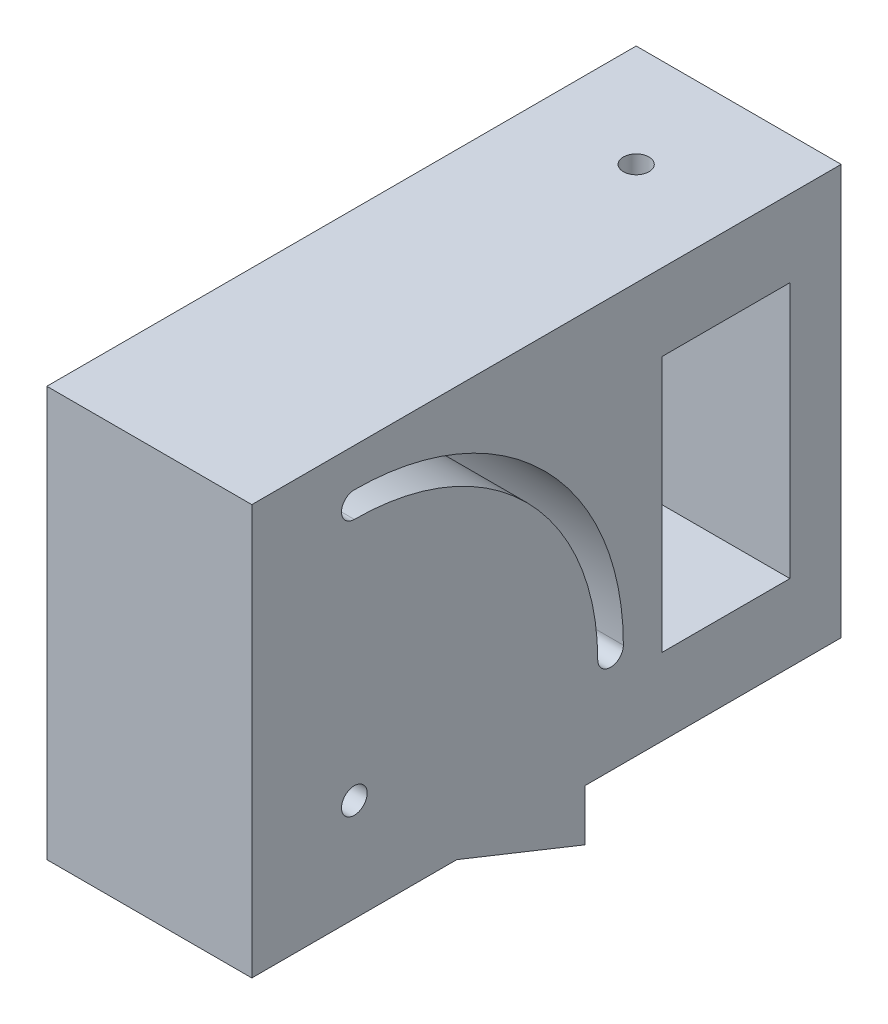
from build123d import *

# Parameters (mm, degrees)
SALIENTE_EXTRUIR1_DEPTH           = 40
CROQUIS2_W                        = 40
CROQUIS2_H                        = 80
SALIENTE_EXTRUIR2_DEPTH           = 50
CORTAR_EXTRUIR1_DEPTH             = 41
CROQUIS4_W                        = 25.000000038
CROQUIS4_H                        = 50
CORTAR_EXTRUIR2_DEPTH             = 41
DI_METRO_DE_TALADRO_5_0_5_1_D     = 5
DI_METRO_DE_TALADRO_5_0_5_1_DEPTH = 25.000025
DI_METRO_DE_TALADRO_5_0_5_2_D     = 5
DI_METRO_DE_TALADRO_5_0_5_2_DEPTH = 40.00005
DI_METRO_DE_TALADRO_5_0_5_3_D     = 5
DI_METRO_DE_TALADRO_5_0_5_3_DEPTH = 90.000025


with BuildPart() as part:
    # Croquis1 → Saliente-Extruir1 (new body)
    with BuildSketch(Plane(origin=(-40, 0, 0), x_dir=(0, -1, 0), z_dir=(-1, 0, 0))):
        Polygon((-37.940430416, 40), (-37.940430416, -25), (52.059569584, -25), (42.059569584, 0), (42.059569584, 40), align=None)
    extrude(amount=-SALIENTE_EXTRUIR1_DEPTH)

    # Croquis2 → Saliente-Extruir2 (add)
    with BuildSketch(Plane(origin=(0, 0, -25), x_dir=(-1, 0, 0), z_dir=(0, 0, -1))):
        with Locations((20, -2.059569584)):
            Rectangle(CROQUIS2_W, CROQUIS2_H)
    extrude(amount=SALIENTE_EXTRUIR2_DEPTH)

    # Croquis3 → Cortar-Extruir1 (cut, through all)
    with BuildSketch(Plane.ZY.offset(40)):
        with BuildLine():
            ThreePointArc((-32.5, -22.059569584), (-30, -24.559569584), (-27.5, -22.059569584))
            ThreePointArc((-27.5, -22.059569584), (-13.587572106, 11.528002522), (20, 25.440430416))
            ThreePointArc((20, 25.440430416), (22.5, 27.940430416), (20, 30.440430416))
            ThreePointArc((20, 30.440430416), (-17.123106012, 15.063536428), (-32.5, -22.059569584))
        make_face()
    extrude(amount=-CORTAR_EXTRUIR1_DEPTH, mode=Mode.SUBTRACT)

    # Croquis4 → Cortar-Extruir2 (cut, through all)
    with BuildSketch(Plane(origin=(0, 0, 0), x_dir=(0, 0, -1), z_dir=(1, 0, 0))):
        with Locations((52.499999981, -2.059569584)):
            Rectangle(CROQUIS4_W, CROQUIS4_H)
    extrude(amount=-CORTAR_EXTRUIR2_DEPTH, mode=Mode.SUBTRACT)

    # Diámetro de taladro Ø5.0 (5)1
    with Locations(Plane(origin=(0, -27.059569584, 0), x_dir=(1, 0, 0), z_dir=(0, 1, 0))):
        with Locations((-20, 55)):
            Hole(DI_METRO_DE_TALADRO_5_0_5_1_D / 2, depth=DI_METRO_DE_TALADRO_5_0_5_1_DEPTH)

    # Diámetro de taladro Ø5.0 (5)2
    with Locations(Plane(origin=(0, 0, 0), x_dir=(0, 0, -1), z_dir=(1, 0, 0))):
        with Locations((-20, -22.059569584)):
            Hole(DI_METRO_DE_TALADRO_5_0_5_2_D / 2, depth=DI_METRO_DE_TALADRO_5_0_5_2_DEPTH)

    # Diámetro de taladro Ø5.0 (5)3
    with Locations(Plane(origin=(0, 37.940430416, 0), x_dir=(1, 0, 0), z_dir=(0, 1, 0))):
        with Locations((-20, 55)):
            Hole(DI_METRO_DE_TALADRO_5_0_5_3_D / 2, depth=DI_METRO_DE_TALADRO_5_0_5_3_DEPTH)


solid = part.part
